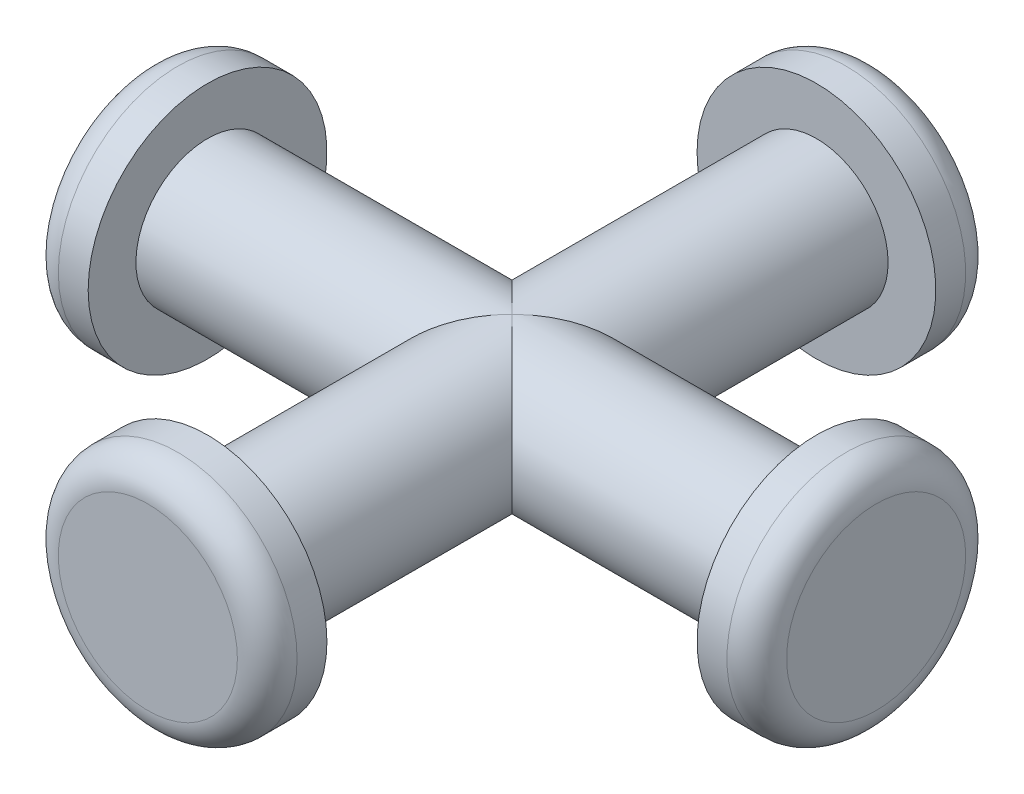
from build123d import *

# Parameters (mm, degrees)
ESQUISSE1_R        = 2.4
BOSS_EXTRU_1_DEPTH = 10.2
ESQUISSE3_R        = 2.4
BOSS_EXTRU_2_DEPTH = 10.2
ESQUISSE4_R        = 4
BOSS_EXTRU_3_DEPTH = 2
ESQUISSE5_R        = 4
BOSS_EXTRU_4_DEPTH = 2
ESQUISSE6_R        = 4
BOSS_EXTRU_5_DEPTH = 2
ESQUISSE7_R        = 4
BOSS_EXTRU_6_DEPTH = 2
CONG_1_R           = 1


with BuildPart() as part:
    # Esquisse1 → Boss.-Extru.1 (new body, symmetric)
    with BuildSketch(Plane.XY):
        Circle(ESQUISSE1_R)
    extrude(amount=BOSS_EXTRU_1_DEPTH, both=True)

    # Esquisse3 → Boss.-Extru.2 (add, symmetric)
    with BuildSketch(Plane(origin=(0, 0, 0), x_dir=(0, 0, -1), z_dir=(1, 0, 0))):
        with Locations(Location((0, 0, 0), (0, 0, 270))):  # turned: the seam where the file's is
            Circle(ESQUISSE3_R)
    extrude(amount=BOSS_EXTRU_2_DEPTH, both=True)

    # Esquisse4 → Boss.-Extru.3 (add)
    with BuildSketch(Plane(origin=(10.2, 0, 0), x_dir=(0, 0, -1), z_dir=(1, 0, 0))):
        Circle(ESQUISSE4_R)
    extrude(amount=BOSS_EXTRU_3_DEPTH)

    # Esquisse5 → Boss.-Extru.4 (add)
    with BuildSketch(Plane.ZY.offset(10.2)):
        with Locations(Location((0, 0, 0), (0, 0, 180))):  # turned: the seam where the file's is
            Circle(ESQUISSE5_R)
    extrude(amount=BOSS_EXTRU_4_DEPTH)

    # Esquisse6 → Boss.-Extru.5 (add)
    with BuildSketch(Plane.XY.offset(10.2)):
        Circle(ESQUISSE6_R)
    extrude(amount=BOSS_EXTRU_5_DEPTH)

    # Esquisse7 → Boss.-Extru.6 (add)
    with BuildSketch(Plane(origin=(0, 0, -10.2), x_dir=(-1, 0, 0), z_dir=(0, 0, -1))):
        with Locations(Location((0, 0, 0), (0, 0, 180))):  # turned: the seam where the file's is
            Circle(ESQUISSE7_R)
    extrude(amount=BOSS_EXTRU_6_DEPTH)

    # Congé1
    cong_1_edges = [part.edges().sort_by_distance(p)[0] for p in [
        (12.2, 0, 4),
        (-12.2, 0, 4),
        (-4, 0, 12.2),
        (-4, 0, -12.2),
    ]]
    fillet(cong_1_edges, radius=CONG_1_R)


solid = part.part
